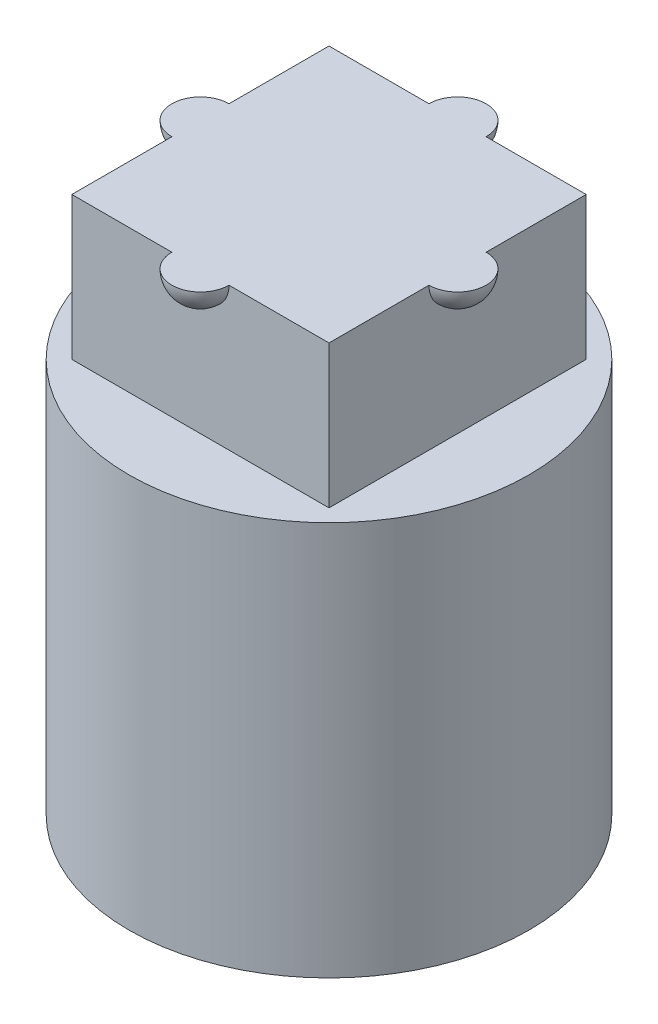
from build123d import *

# Parameters (mm, degrees)
SKETCH_1_R          = 3.5
EXTRUDE_1_DEPTH     = 4
SKETCH_3_R          = 3.5
EXTRUDE_2_DEPTH     = 2.9
SKETCH_4_W          = 4.5
SKETCH_4_H          = 4.5
EXTRUDE_3_DEPTH     = 2.5
SKETCH_7_R          = 3.5
CUT_EXTRUDE_1_DEPTH = 10


with BuildPart() as part:
    # 草图1 → 凸台-拉伸1 (new body)
    with BuildSketch(Plane(origin=(0, 0, 0), x_dir=(1, 0, 0), z_dir=(0, 1, 0))):
        Circle(SKETCH_1_R)
        with BuildLine():
            Line((-2.25, 2.25), (-0.4, 2.25))
            ThreePointArc((-0.4, 2.25), (0, 2.65), (0.4, 2.25))
            Line((0.4, 2.25), (2.25, 2.25))
            Line((2.25, 2.25), (2.25, 0.4))
            ThreePointArc((2.25, 0.4), (2.65, 0), (2.25, -0.4))
            Line((2.25, -0.4), (2.25, -2.25))
            Line((2.25, -2.25), (0.4, -2.25))
            ThreePointArc((0.4, -2.25), (0, -2.65), (-0.4, -2.25))
            Line((-0.4, -2.25), (-2.25, -2.25))
            Line((-2.25, -2.25), (-2.25, -0.4))
            ThreePointArc((-2.25, -0.4), (-2.65, 0), (-2.25, 0.4))
            Line((-2.25, 0.4), (-2.25, 2.25))
        make_face(mode=Mode.SUBTRACT)
    extrude(amount=EXTRUDE_1_DEPTH)

    # 草图3 → 凸台-拉伸2 (add)
    with BuildSketch(Plane(origin=(0, 4, 0), x_dir=(1, 0, 0), z_dir=(0, 1, 0))):
        Circle(SKETCH_3_R)
    extrude(amount=EXTRUDE_2_DEPTH)

    # 草图4 → 凸台-拉伸3 (add)
    with BuildSketch(Plane(origin=(0, 6.9, 0), x_dir=(1, 0, 0), z_dir=(0, 1, 0))):
        Rectangle(SKETCH_4_W, SKETCH_4_H)
    extrude(amount=EXTRUDE_3_DEPTH)

    # 草图5 → 旋转1 (revolve)
    with BuildSketch(Plane(origin=(0, 9.4, 0), x_dir=(1, 0, 0), z_dir=(0, 1, 0))):
        with BuildLine():
            Line((-2.75, 0), (-1.75, 0))
            ThreePointArc((-1.75, 0), (-2.25, -0.5), (-2.75, 0))
        make_face()
        with BuildLine():
            Line((1.75, 0), (2.75, 0))
            ThreePointArc((2.75, 0), (2.25, -0.5), (1.75, 0))
        make_face()
    revolve(axis=Axis((-2.75, 9.4, 0), (1, 0, 0)))

    # 草图6 → 旋转2 (revolve)
    with BuildSketch(Plane(origin=(0, 9.4, 0), x_dir=(1, 0, 0), z_dir=(0, 1, 0))):
        with BuildLine():
            Line((0, -2.75), (0, -1.75))
            ThreePointArc((0, -1.75), (-0.5, -2.25), (0, -2.75))
        make_face()
        with BuildLine():
            Line((0, 1.75), (0, 2.75))
            ThreePointArc((0, 2.75), (-0.5, 2.25), (0, 1.75))
        make_face()
    revolve(axis=Axis((0, 9.4, 2.75), (0, 0, -1)))

    # 草图7 → 切除-拉伸1 (cut)
    with BuildSketch(Plane(origin=(0, 9.4, 0), x_dir=(1, 0, 0), z_dir=(0, 1, 0))):
        Circle(SKETCH_7_R)
    extrude(amount=CUT_EXTRUDE_1_DEPTH, mode=Mode.SUBTRACT)


solid = part.part
